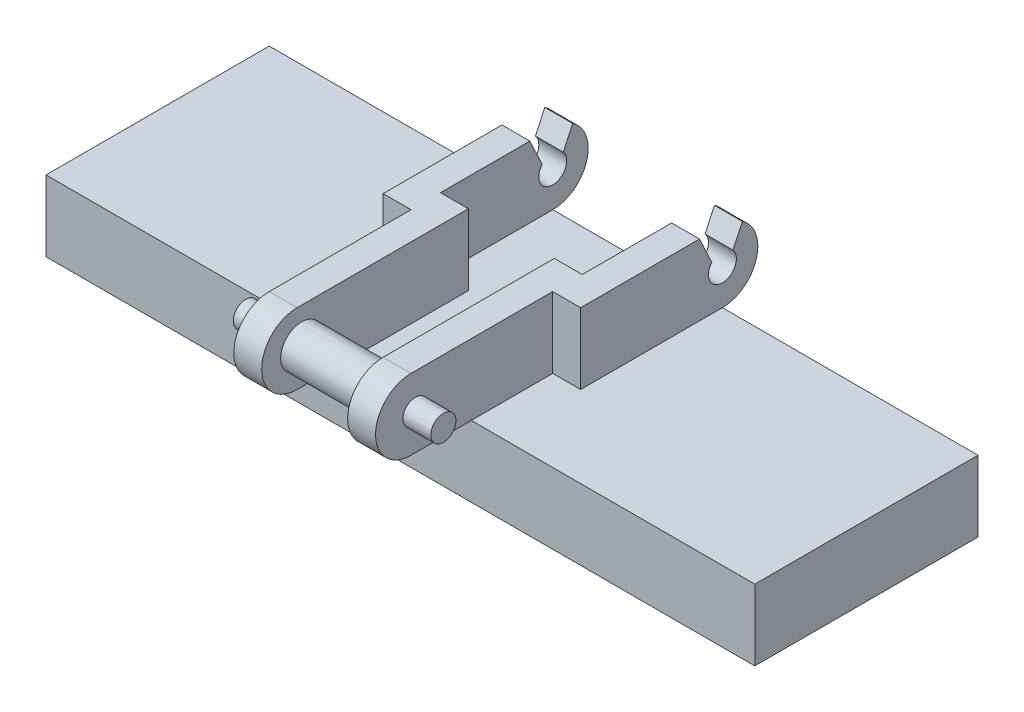
from build123d import *

# Parameters (mm, degrees)
SKETCH1_W                        = 25.4
SKETCH1_H                        = 5.08
BOSS_EXTRUDE1_DEPTH              = 2.54
BOSS_EXTRUDE5_DEPTH              = 2.54
SKETCH6_R                        = 1.27
BOSS_EXTRUDE6_DEPTH              = 1
BOSS_EXTRUDE7_DEPTH              = 1
SKETCH8_W                        = 25.4
SKETCH8_H                        = 8
BOSS_EXTRUDE8_DEPTH              = 2.54
SKETCH11_R                       = 0.5
CUT_EXTRUDE1_DEPTH               = 17.24
CUT_EXTRUDE2_DEPTH               = 10.54
SKETCH2_W                        = 1
SKETCH2_H                        = 4.46
BOSS_EXTRUDE2_DEPTH              = 2.54
SKETCH13_R                       = 0.75
BOSS_EXTRUDE12_DEPTH             = 3.08
CUT_EXTRUDE3_DEPTH               = 9
BOSS_EXTRUDE13_REACH             = 12.16
SKETCH16_R                       = 0.45
BOSS_EXTRUDE13_DIRECTION_2_REACH = 17.24


with BuildPart() as part:
    # Sketch1 → Boss-Extrude1 (new body)
    with BuildSketch(Plane(origin=(0, 0, 0), x_dir=(1, 0, 0), z_dir=(0, 1, 0))):
        Rectangle(SKETCH1_W, SKETCH1_H)
    extrude(amount=BOSS_EXTRUDE1_DEPTH)

    # Sketch5 → Boss-Extrude5 (add)
    with BuildSketch(Plane(origin=(0, 2.54, 0), x_dir=(1, 0, 0), z_dir=(0, 1, 0))):
        Polygon((-3.54, 2.54), (-3.54, -2.54), (-2.54, -2.54), (-2.54, -7.62), (-1.54, -7.62), (-1.54, -1.482742514), (-2.54, -1.482742514), (-2.54, 2.54), align=None)
    boss_extrude5 = extrude(amount=BOSS_EXTRUDE5_DEPTH)

    # Sketch6 → Boss-Extrude6 (add)
    with BuildSketch(Plane(origin=(-1.54, 0, 0), x_dir=(0, 0, -1), z_dir=(1, 0, 0))):
        with Locations((-7.62, 3.81)):
            Circle(SKETCH6_R)
    boss_extrude6 = extrude(amount=-BOSS_EXTRUDE6_DEPTH)

    # Sketch7 → Boss-Extrude7 (add)
    with BuildSketch(Plane(origin=(-2.54, 0, 0), x_dir=(0, 0, -1), z_dir=(1, 0, 0))):
        with BuildLine():
            Line((2.54, 5.08), (2.54, 2.54))
            ThreePointArc((2.54, 2.54), (3.81, 3.81), (2.54, 5.08))
        make_face()
    boss_extrude7 = extrude(amount=-BOSS_EXTRUDE7_DEPTH)

    # Mirror1: Boss-Extrude5, Boss-Extrude6, Boss-Extrude7 across plane
    add(boss_extrude5.mirror(Plane(origin=(0, 0, 0), x_dir=(0, 0, 1), z_dir=(1, 0, 0))))
    add(boss_extrude6.mirror(Plane(origin=(0, 0, 0), x_dir=(0, 0, 1), z_dir=(1, 0, 0))))
    add(boss_extrude7.mirror(Plane(origin=(0, 0, 0), x_dir=(0, 0, 1), z_dir=(1, 0, 0))))

    # Sketch8 → Boss-Extrude8 (add)
    with BuildSketch(Plane.XZ.offset(-2.54)):
        with Locations((0, 1.46)):
            Rectangle(SKETCH8_W, SKETCH8_H)
    extrude(amount=BOSS_EXTRUDE8_DEPTH)

    # Sketch11 → Cut-Extrude1 (cut, through all)
    with BuildSketch(Plane(origin=(3.54, 0, 0), x_dir=(0, 0, -1), z_dir=(1, 0, 0))):
        with Locations((2.54, 3.81)):
            Circle(SKETCH11_R)
    extrude(amount=-CUT_EXTRUDE1_DEPTH, mode=Mode.SUBTRACT)

    # Sketch12 → Cut-Extrude2 (cut)
    with BuildSketch(Plane(origin=(3.54, 0, 0), x_dir=(0, 0, -1), z_dir=(1, 0, 0))):
        with BuildLine():
            Line((1.923817285, 5.08), (1.72030075, 5.08))
            Line((1.72030075, 5.08), (2.177926741, 4.101139391))
            ThreePointArc((2.177926741, 4.101139391), (2.54, 3.34539351), (2.902073259, 4.101139391))
            Line((2.902073259, 4.101139391), (3.256261376, 4.8587467))
            ThreePointArc((3.256261376, 4.8587467), (2.914827754, 5.023426617), (2.54, 5.08))
            Line((2.54, 5.08), (1.923817285, 5.08))
        make_face()
    extrude(amount=-CUT_EXTRUDE2_DEPTH, mode=Mode.SUBTRACT)

    # Sketch2 → Boss-Extrude2 (add)
    with BuildSketch(Plane(origin=(0, 2.54, 0), x_dir=(1, 0, 0), z_dir=(0, 1, 0))):
        with Locations((-3.04, -0.31)):
            Rectangle(SKETCH2_W, SKETCH2_H)
        with Locations((3.04, -0.31)):
            Rectangle(SKETCH2_W, SKETCH2_H)
    extrude(amount=BOSS_EXTRUDE2_DEPTH)

    # Sketch13 → Boss-Extrude12 (add)
    with BuildSketch(Plane.ZY.offset(-1.54)):
        with Locations((7.46, 3.81)):
            Circle(SKETCH13_R)
    extrude(amount=BOSS_EXTRUDE12_DEPTH)

    # Sketch14 → Cut-Extrude3 (cut)
    with BuildSketch(Plane(origin=(3.54, 0, 0), x_dir=(0, 0, -1), z_dir=(1, 0, 0))):
        Polygon((1.92, 4.652843909), (1.72030075, 5.08), (1.92, 5.08), align=None)
    extrude(amount=-CUT_EXTRUDE3_DEPTH, mode=Mode.SUBTRACT)

    # Boss-Extrude13: up to this face of the body (flat: up to its plane)
    boss_extrude13_end = Plane(part.part.faces().sort_by_distance((-3.54, 3.747341049, -0.245716728))[0])
    # Sketch16 → Boss-Extrude13 (add, up to the picked face)
    with BuildSketch(Plane.ZY.offset(2.54), mode=Mode.PRIVATE) as boss_extrude13_sk1:
        with Locations((7.46, 3.81)):
            Circle(SKETCH16_R)
    boss_extrude13_tool1 = split(extrude(boss_extrude13_sk1.sketch, amount=BOSS_EXTRUDE13_REACH, mode=Mode.PRIVATE), bisect_by=boss_extrude13_end, keep=Keep.BOTH, mode=Mode.PRIVATE)
    add(boss_extrude13_tool1.solids().sort_by_distance((-2.54, 3.81, 7.46))[0])

    # Boss-Extrude13 direction 2: up to this face of the body (flat: up to its plane)
    boss_extrude13_direction_2_end = Plane(part.part.faces().sort_by_distance((3.54, 3.747341049, -0.245716728))[0])
    # Sketch16 → Boss-Extrude13 direction 2 (add, up to the picked face)
    with BuildSketch(Plane.ZY.offset(2.54), mode=Mode.PRIVATE) as boss_extrude13_direction_2_sk1:
        with Locations((7.46, 3.81)):
            Circle(SKETCH16_R)
    boss_extrude13_direction_2_tool1 = split(extrude(boss_extrude13_direction_2_sk1.sketch, amount=-BOSS_EXTRUDE13_DIRECTION_2_REACH, mode=Mode.PRIVATE), bisect_by=boss_extrude13_direction_2_end, keep=Keep.BOTH, mode=Mode.PRIVATE)
    add(boss_extrude13_direction_2_tool1.solids().sort_by_distance((-2.54, 3.81, 7.46))[0])


solid = part.part
